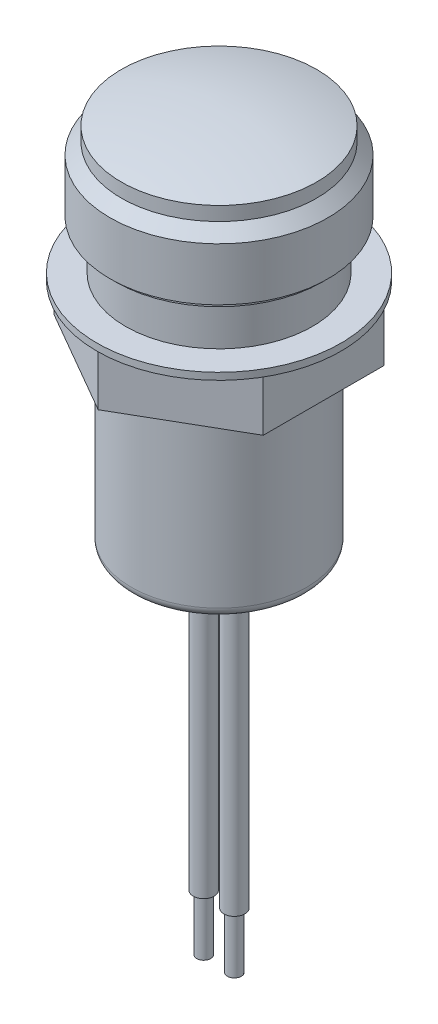
from build123d import *

# Parameters (mm, degrees)
DOME1_FACE_RADIUS   = 8.89
DOME1_HEIGHT        = 1.27
SKETCH2_OUTSIDE_W   = 33.908
SKETCH2_OUTSIDE_H   = 33.908
CUT_EXTRUDE1_DEPTH  = 4.6736
SKETCH3_R           = 0.9525
BOSS_EXTRUDE1_DEPTH = 25.4
SKETCH4_R           = 0.635
BOSS_EXTRUDE2_DEPTH = 5.08
FILLET1_R           = 0.889
FILLET2_R           = 0.381


with BuildPart() as part:
    # Sketch1 → Revolve1 (revolve)
    with BuildSketch(Plane.XY):
        Polygon((0, 35.56), (8.89, 35.56), (8.89, 34.29), (9.9187, 33.2613), (9.9187, 28.448), (9.40435, 28.448), (9.40435, 27.94), (8.5, 27.94), (8.5, 23.9776), (11.1125, 23.9776), (11.1125, 18.669), (7.992, 18.669), (7.992, 2.286), (3.81, 2.286), (3.81, 0), (0, 0), align=None)
    revolve(axis=Axis((0, 0, 0), (0, 1, 0)))

    # Dome1: a dome of height H over a round flat face of radius A is a cap of a sphere of radius (A * A + H * H) / (2 * H)
    dome1_r = (DOME1_FACE_RADIUS * DOME1_FACE_RADIUS + DOME1_HEIGHT * DOME1_HEIGHT) / (2 * DOME1_HEIGHT)
    dome1_base = Plane((0, 35.56, 0), z_dir=(0, 1, 0))
    with Locations(dome1_base.offset(DOME1_HEIGHT - dome1_r)):
        dome1_ball = Sphere(dome1_r, mode=Mode.PRIVATE)
    add(split(dome1_ball, bisect_by=dome1_base, keep=Keep.TOP, mode=Mode.PRIVATE))

    # Sketch2 outside → Cut-Extrude1 (cut)
    with BuildSketch(Plane.XZ.offset(-18.669)):
        Rectangle(SKETCH2_OUTSIDE_W, SKETCH2_OUTSIDE_H)
        Polygon((0, 10.998522628), (-9.525, 5.499261314), (-9.525, -5.499261314), (0, -10.998522628), (9.525, -5.499261314), (9.525, 5.499261314), align=None, mode=Mode.SUBTRACT)
    extrude(amount=-CUT_EXTRUDE1_DEPTH, mode=Mode.SUBTRACT)

    # Sketch3 → Boss-Extrude1 (add)
    with BuildSketch(Plane.XZ):
        with Locations((-1.397, 0)):
            Circle(SKETCH3_R)
        with Locations((1.397, 0)):
            Circle(SKETCH3_R)
    extrude(amount=BOSS_EXTRUDE1_DEPTH)

    # Sketch4 → Boss-Extrude2 (add)
    with BuildSketch(Plane.XZ.offset(25.4)):
        with Locations((1.397, 0)):
            Circle(SKETCH4_R)
        with Locations((-1.397, 0)):
            Circle(SKETCH4_R)
    extrude(amount=BOSS_EXTRUDE2_DEPTH)

    # Fillet1
    fillet1_edges = [part.edges().sort_by_distance(p)[0] for p in [
        (-7.992, 2.286, 0),
    ]]
    fillet(fillet1_edges, radius=FILLET1_R)

    # Fillet2
    fillet2_edges = [part.edges().sort_by_distance(p)[0] for p in [
        (-3.81, 0, 0),
        (-3.81, 2.286, 0),
    ]]
    fillet(fillet2_edges, radius=FILLET2_R)


solid = part.part
